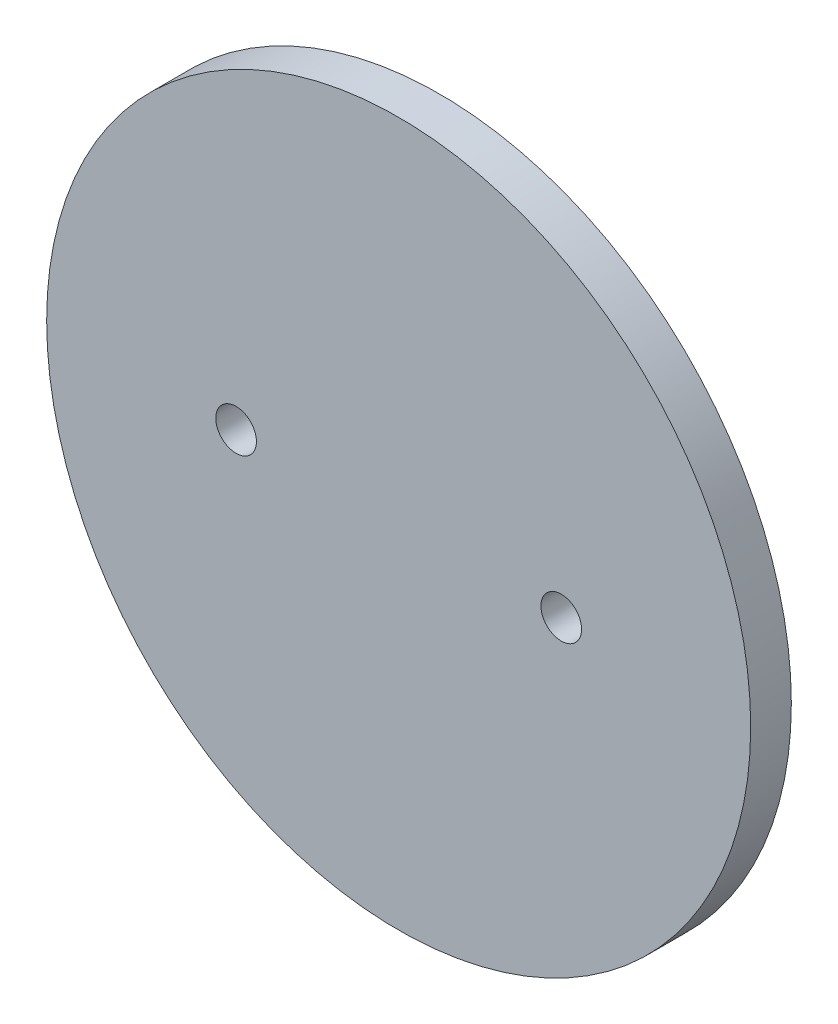
from build123d import *

# Parameters (mm, degrees)
SKETCH1_R           = 22
BOSS_EXTRUDE1_DEPTH = 2.54
CUT_EXTRUDE1_DEPTH  = 3.54


with BuildPart() as part:
    # Sketch1 → Boss-Extrude1 (new body)
    with BuildSketch(Plane.XY):
        Circle(SKETCH1_R)
    extrude(amount=BOSS_EXTRUDE1_DEPTH)

    # Sketch2 → Cut-Extrude1 (cut, through all)
    with BuildSketch(Plane.XY.offset(2.54)):
        with BuildLine():
            ThreePointArc((-8.89, 0), (-10.16, 1.27), (-11.43, 0))
            Line((-11.43, 0), (-8.89, 0))
        make_face()
        with BuildLine():
            Line((-8.89, 0), (-11.43, 0))
            ThreePointArc((-11.43, 0), (-10.16, -1.27), (-8.89, 0))
        make_face()
        with BuildLine():
            ThreePointArc((11.43, 0), (10.16, 1.27), (8.89, 0))
            Line((8.89, 0), (11.43, 0))
        make_face()
        with BuildLine():
            Line((11.43, 0), (8.89, 0))
            ThreePointArc((8.89, 0), (10.16, -1.27), (11.43, 0))
        make_face()
    extrude(amount=-CUT_EXTRUDE1_DEPTH, mode=Mode.SUBTRACT)


solid = part.part
